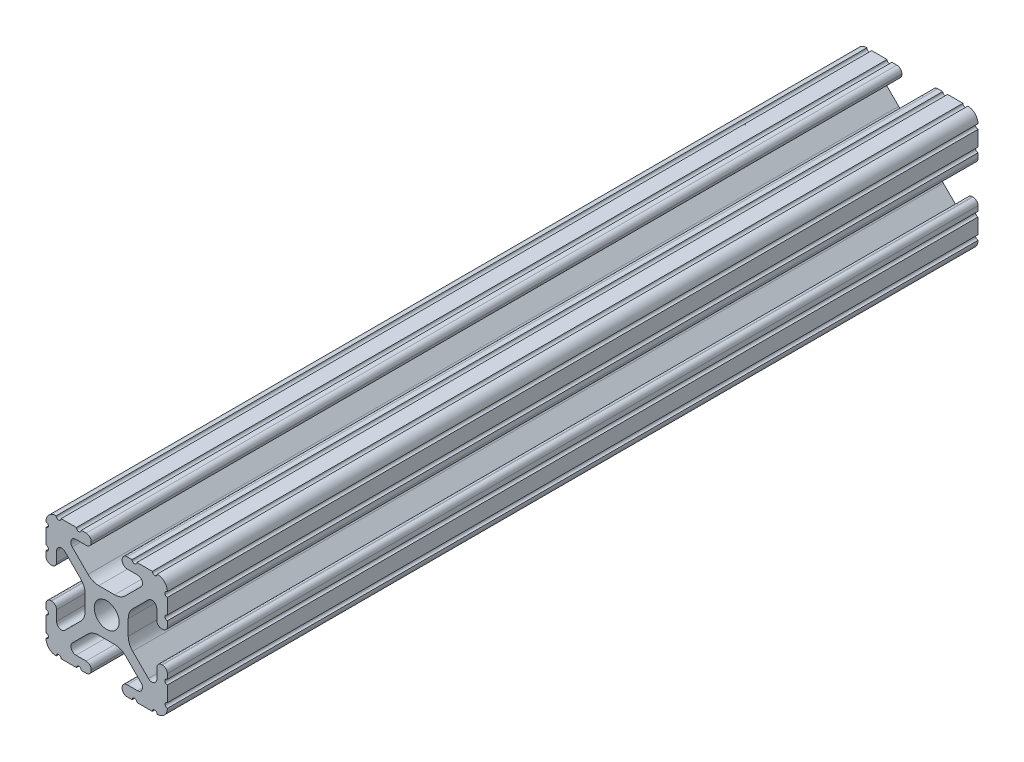
from build123d import *

# Parameters (mm, degrees)
SKETCH1_R           = 2.6035
BOSS_EXTRUDE1_DEPTH = 914.4
SKETCH2_W           = 573.8387108
SKETCH2_H           = 34.760821459
SKETCH2_W_2         = 1099.97900941
SKETCH2_H_2         = 36.169365112
CUT_EXTRUDE1_DEPTH  = 27.432


with BuildPart() as part:
    # Sketch1 → Boss-Extrude1 (new body, symmetric)
    with BuildSketch(Plane.XY):
        with BuildLine():
            Line((-7.179650497, -8.645192506), (-3.952270251, -5.423690499))
            ThreePointArc((-3.952270251, -5.423690499), (-2.922936451, -4.736929036), (-1.709253557, -4.4958))
            Line((-1.709253557, -4.4958), (1.709253557, -4.4958))
            ThreePointArc((1.709253557, -4.4958), (2.922936451, -4.736929036), (3.952270251, -5.423690499))
            Line((3.952270251, -5.423690499), (7.179650497, -8.645192506))
            ThreePointArc((7.179650497, -8.645192506), (7.41473083, -9.822813117), (6.416408329, -10.4902))
            Line((6.416408329, -10.4902), (4.287512407, -10.4902))
            ThreePointArc((4.287512407, -10.4902), (3.54574862, -10.79744862), (3.2385, -11.539212407))
            Line((3.2385, -11.539212407), (3.2385, -11.650987593))
            ThreePointArc((3.2385, -11.650987593), (3.54574862, -12.39275138), (4.287512407, -12.7))
            Line((4.287512407, -12.7), (5.317126718, -12.7))
            ThreePointArc((5.317126718, -12.7), (5.825126718, -12.192), (6.333126718, -12.7))
            Line((6.333126718, -12.7), (9.550443118, -12.7))
            ThreePointArc((9.550443118, -12.7), (10.058366869, -12.192000006), (10.566443095, -12.699847501))
            ThreePointArc((10.566443095, -12.699847501), (12.082537762, -12.08250727), (12.699846982, -10.566399977))
            ThreePointArc((12.699846982, -10.566399977), (12.192000006, -10.058323491), (12.7, -9.5504))
            Line((12.7, -9.5504), (12.7, -6.3330836))
            ThreePointArc((12.7, -6.3330836), (12.192, -5.8250836), (12.7, -5.3170836))
            Line((12.7, -5.3170836), (12.7, -4.287469289))
            ThreePointArc((12.7, -4.287469289), (12.39275138, -3.545705502), (11.650987593, -3.238456882))
            Line((11.650987593, -3.238456882), (11.539212407, -3.238456882))
            ThreePointArc((11.539212407, -3.238456882), (10.79744862, -3.545705502), (10.4902, -4.287469289))
            Line((10.4902, -4.287469289), (10.4902, -6.402089023))
            ThreePointArc((10.4902, -6.402089023), (9.856505071, -7.351067942), (8.737131347, -7.129408934))
            Line((8.737131347, -7.129408934), (5.441005833, -3.840816462))
            ThreePointArc((5.441005833, -3.840816462), (4.750877967, -2.809883091), (4.5085, -1.593185507))
            Line((4.5085, -1.593185507), (4.5085, 1.593185507))
            ThreePointArc((4.5085, 1.593185507), (4.750877967, 2.809883091), (5.441005833, 3.840816462))
            Line((5.441005833, 3.840816462), (8.737131347, 7.129408934))
            ThreePointArc((8.737131347, 7.129408934), (9.856505071, 7.351067942), (10.4902, 6.402089023))
            Line((10.4902, 6.402089023), (10.4902, 4.287469289))
            ThreePointArc((10.4902, 4.287469289), (10.79744862, 3.545705502), (11.539212407, 3.238456882))
            Line((11.539212407, 3.238456882), (11.650987593, 3.238456882))
            ThreePointArc((11.650987593, 3.238456882), (12.39275138, 3.545705502), (12.7, 4.287469289))
            Line((12.7, 4.287469289), (12.7, 5.3170836))
            ThreePointArc((12.7, 5.3170836), (12.192, 5.8250836), (12.7, 6.3330836))
            Line((12.7, 6.3330836), (12.7, 9.5504))
            ThreePointArc((12.7, 9.5504), (12.192000006, 10.058323491), (12.699846982, 10.566399977))
            ThreePointArc((12.699846982, 10.566399977), (12.082537762, 12.08250727), (10.566443095, 12.699847501))
            ThreePointArc((10.566443095, 12.699847501), (10.058366869, 12.192000006), (9.550443118, 12.7))
            Line((9.550443118, 12.7), (6.333126718, 12.7))
            ThreePointArc((6.333126718, 12.7), (5.825126718, 12.192), (5.317126718, 12.7))
            Line((5.317126718, 12.7), (4.287512407, 12.7))
            ThreePointArc((4.287512407, 12.7), (3.54574862, 12.39275138), (3.2385, 11.650987593))
            Line((3.2385, 11.650987593), (3.2385, 11.539212407))
            ThreePointArc((3.2385, 11.539212407), (3.54574862, 10.79744862), (4.287512407, 10.4902))
            Line((4.287512407, 10.4902), (6.476788598, 10.4902))
            ThreePointArc((6.476788598, 10.4902), (7.432222385, 9.85140422), (7.207036008, 8.724370562))
            Line((7.207036008, 8.724370562), (3.898272566, 5.423169045))
            ThreePointArc((3.898272566, 5.423169045), (2.869120213, 4.736787962), (1.655778399, 4.4958))
            Line((1.655778399, 4.4958), (-1.655778399, 4.4958))
            ThreePointArc((-1.655778399, 4.4958), (-2.869120213, 4.736787962), (-3.898272566, 5.423169045))
            Line((-3.898272566, 5.423169045), (-7.207036008, 8.724370562))
            ThreePointArc((-7.207036008, 8.724370562), (-7.432222385, 9.85140422), (-6.476788598, 10.4902))
            Line((-6.476788598, 10.4902), (-4.287512407, 10.4902))
            ThreePointArc((-4.287512407, 10.4902), (-3.54574862, 10.79744862), (-3.2385, 11.539212407))
            Line((-3.2385, 11.539212407), (-3.2385, 11.650987593))
            ThreePointArc((-3.2385, 11.650987593), (-3.54574862, 12.39275138), (-4.287512407, 12.7))
            Line((-4.287512407, 12.7), (-5.317126718, 12.7))
            ThreePointArc((-5.317126718, 12.7), (-5.825126718, 12.192), (-6.333126718, 12.7))
            Line((-6.333126718, 12.7), (-9.550443118, 12.7))
            ThreePointArc((-9.550443118, 12.7), (-10.058366869, 12.192000006), (-10.566443095, 12.699847501))
            ThreePointArc((-10.566443095, 12.699847501), (-12.082537762, 12.08250727), (-12.699846982, 10.566399977))
            ThreePointArc((-12.699846982, 10.566399977), (-12.192000006, 10.058323491), (-12.7, 9.5504))
            Line((-12.7, 9.5504), (-12.7, 6.3330836))
            ThreePointArc((-12.7, 6.3330836), (-12.192, 5.8250836), (-12.7, 5.3170836))
            Line((-12.7, 5.3170836), (-12.7, 4.287469289))
            ThreePointArc((-12.7, 4.287469289), (-12.39275138, 3.545705502), (-11.650987593, 3.238456882))
            Line((-11.650987593, 3.238456882), (-11.539212407, 3.238456882))
            ThreePointArc((-11.539212407, 3.238456882), (-10.79744862, 3.545705502), (-10.4902, 4.287469289))
            Line((-10.4902, 4.287469289), (-10.4902, 6.402089023))
            ThreePointArc((-10.4902, 6.402089023), (-9.856505071, 7.351067942), (-8.737131347, 7.129408934))
            Line((-8.737131347, 7.129408934), (-5.441005833, 3.840816462))
            ThreePointArc((-5.441005833, 3.840816462), (-4.750877967, 2.809883091), (-4.5085, 1.593185507))
            Line((-4.5085, 1.593185507), (-4.5085, -1.593185507))
            ThreePointArc((-4.5085, -1.593185507), (-4.750877967, -2.809883091), (-5.441005833, -3.840816462))
            Line((-5.441005833, -3.840816462), (-8.737131347, -7.129408934))
            ThreePointArc((-8.737131347, -7.129408934), (-9.856505071, -7.351067942), (-10.4902, -6.402089023))
            Line((-10.4902, -6.402089023), (-10.4902, -4.287469289))
            ThreePointArc((-10.4902, -4.287469289), (-10.79744862, -3.545705502), (-11.539212407, -3.238456882))
            Line((-11.539212407, -3.238456882), (-11.650987593, -3.238456882))
            ThreePointArc((-11.650987593, -3.238456882), (-12.39275138, -3.545705502), (-12.7, -4.287469289))
            Line((-12.7, -4.287469289), (-12.7, -5.3170836))
            ThreePointArc((-12.7, -5.3170836), (-12.192, -5.8250836), (-12.7, -6.3330836))
            Line((-12.7, -6.3330836), (-12.7, -9.5504))
            ThreePointArc((-12.7, -9.5504), (-12.192000006, -10.058323491), (-12.699846982, -10.566399977))
            ThreePointArc((-12.699846982, -10.566399977), (-12.082537762, -12.08250727), (-10.566443095, -12.699847501))
            ThreePointArc((-10.566443095, -12.699847501), (-10.058366869, -12.192000006), (-9.550443118, -12.7))
            Line((-9.550443118, -12.7), (-6.333126718, -12.7))
            ThreePointArc((-6.333126718, -12.7), (-5.825126718, -12.192), (-5.317126718, -12.7))
            Line((-5.317126718, -12.7), (-4.287512407, -12.7))
            ThreePointArc((-4.287512407, -12.7), (-3.54574862, -12.39275138), (-3.2385, -11.650987593))
            Line((-3.2385, -11.650987593), (-3.2385, -11.539212407))
            ThreePointArc((-3.2385, -11.539212407), (-3.54574862, -10.79744862), (-4.287512407, -10.4902))
            Line((-4.287512407, -10.4902), (-6.416408329, -10.4902))
            ThreePointArc((-6.416408329, -10.4902), (-7.41473083, -9.822813117), (-7.179650497, -8.645192506))
        make_face()
        Circle(SKETCH1_R, mode=Mode.SUBTRACT)
    extrude(amount=BOSS_EXTRUDE1_DEPTH, both=True)

    # Sketch2 → Cut-Extrude1 (cut)
    with BuildSketch(Plane(origin=(12.7, 0, 0), x_dir=(0, 0, -1), z_dir=(1, 0, 0))):
        with Locations((-631.537917207, -0.58573738)):
            Rectangle(SKETCH2_W, SKETCH2_H)
        with Locations((375.067711741, 0.118534447)):
            Rectangle(SKETCH2_W_2, SKETCH2_H_2)
    extrude(amount=-CUT_EXTRUDE1_DEPTH, mode=Mode.SUBTRACT)


solid = part.part
